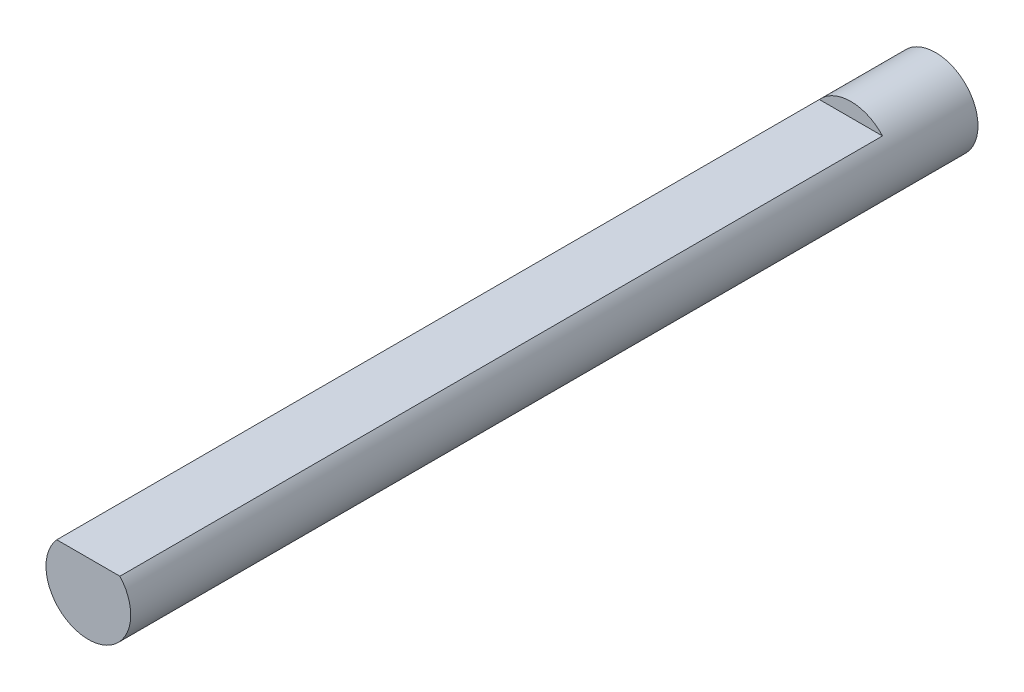
from build123d import *

# Parameters (mm, degrees)
SKETCH1_R           = 1.5
BOSS_EXTRUDE1_DEPTH = 15
CUT_EXTRUDE1_DEPTH  = 27


with BuildPart() as part:
    # Sketch1 → Boss-Extrude1 (new body, symmetric)
    with BuildSketch(Plane.XY):
        Circle(SKETCH1_R)
    extrude(amount=BOSS_EXTRUDE1_DEPTH, both=True)

    # Sketch2 → Cut-Extrude1 (cut)
    with BuildSketch(Plane.XY.offset(15)):
        with BuildLine():
            Line((1.118033989, 1), (-1.118033989, 1))
            ThreePointArc((-1.118033989, 1), (0, 1.5), (1.118033989, 1))
        make_face()
    extrude(amount=-CUT_EXTRUDE1_DEPTH, mode=Mode.SUBTRACT)


solid = part.part
